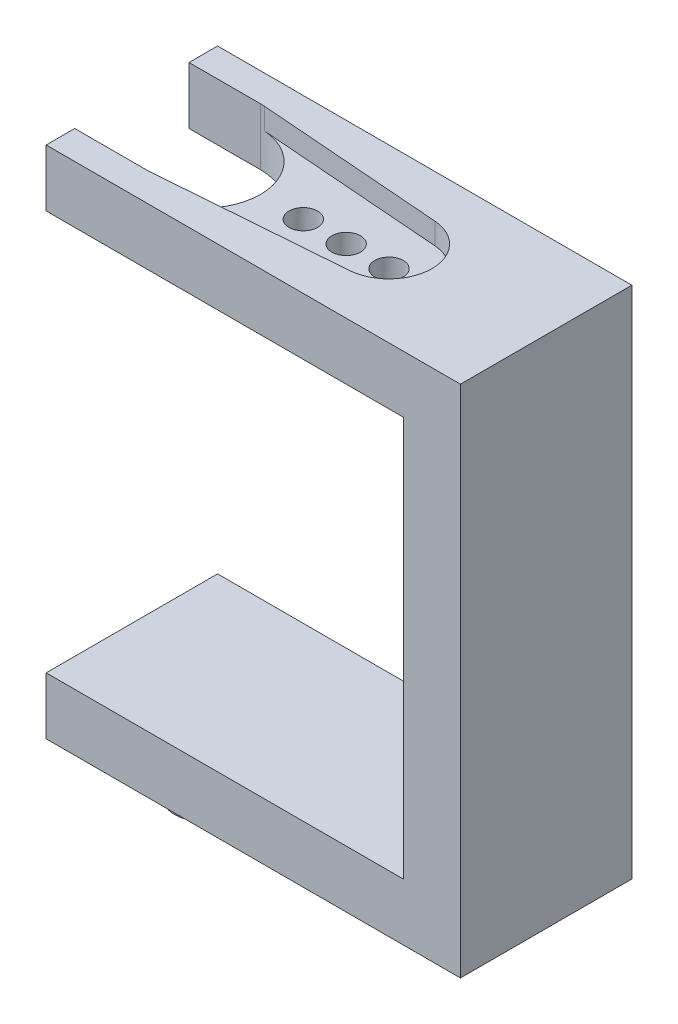
from build123d import *

# Parameters (mm, degrees)
EXTRUDE_1_DEPTH     = 12
CUT_EXTRUDE_1_DEPTH = 5.1
CUT_EXTRUDE_2_DEPTH = 1.5
SKETCH_4_3_R        = 1
CUT_EXTRUDE_3_DEPTH = 6.5
SKETCH_2_R          = 2
EXTRUDE_2_DEPTH     = 4.1


with BuildPart() as part:
    # 草图1 → 凸台-拉伸1 (new body)
    with BuildSketch(Plane.XY):
        Polygon((0, 0), (25, 0), (25, 28), (0, 28), (0, 32), (29, 32), (29, -4), (0, -4), align=None)
    extrude(amount=EXTRUDE_1_DEPTH)

    # 草图3 → 切除-拉伸1 (cut)
    with BuildSketch(Plane(origin=(0, 32, 0), x_dir=(1, 0, 0), z_dir=(0, 1, 0))):
        with BuildLine():
            Line((5, -2), (0, -2))
            Line((0, -2), (0, -10))
            Line((0, -10), (5, -10))
            ThreePointArc((5, -10), (9, -6), (5, -2))
        make_face()
    extrude(amount=-CUT_EXTRUDE_1_DEPTH, mode=Mode.SUBTRACT)

    # 草图4 → 切除-拉伸2 (cut)
    with BuildSketch(Plane(origin=(0, 32, 0), x_dir=(1, 0, 0), z_dir=(0, 1, 0))):
        with BuildLine():
            ThreePointArc((5.307692308, -2.011851878), (9, -6), (5.307692308, -9.988148122))
            Line((5.307692308, -9.988148122), (18.230769231, -8.991111092))
            ThreePointArc((18.230769231, -8.991111092), (21, -6), (18.230769231, -3.008888908))
            Line((18.230769231, -3.008888908), (5.307692308, -2.011851878))
        make_face()
    extrude(amount=-CUT_EXTRUDE_2_DEPTH, mode=Mode.SUBTRACT)

    # 草图4<3> → 切除-拉伸3 (cut)
    with BuildSketch(Plane(origin=(0, 32, 0), x_dir=(1, 0, 0), z_dir=(0, 1, 0))):
        with Locations((12, -6)):
            Circle(SKETCH_4_3_R)
        with Locations((18, -6)):
            Circle(SKETCH_4_3_R)
        with Locations((15, -6)):
            Circle(SKETCH_4_3_R)
    extrude(amount=-CUT_EXTRUDE_3_DEPTH, mode=Mode.SUBTRACT)

    # 草图2 → 凸台-拉伸2 (add)
    with BuildSketch(Plane.XZ.offset(4)):
        with Locations((5, 6)):
            Circle(SKETCH_2_R)
    extrude(amount=EXTRUDE_2_DEPTH)


solid = part.part
